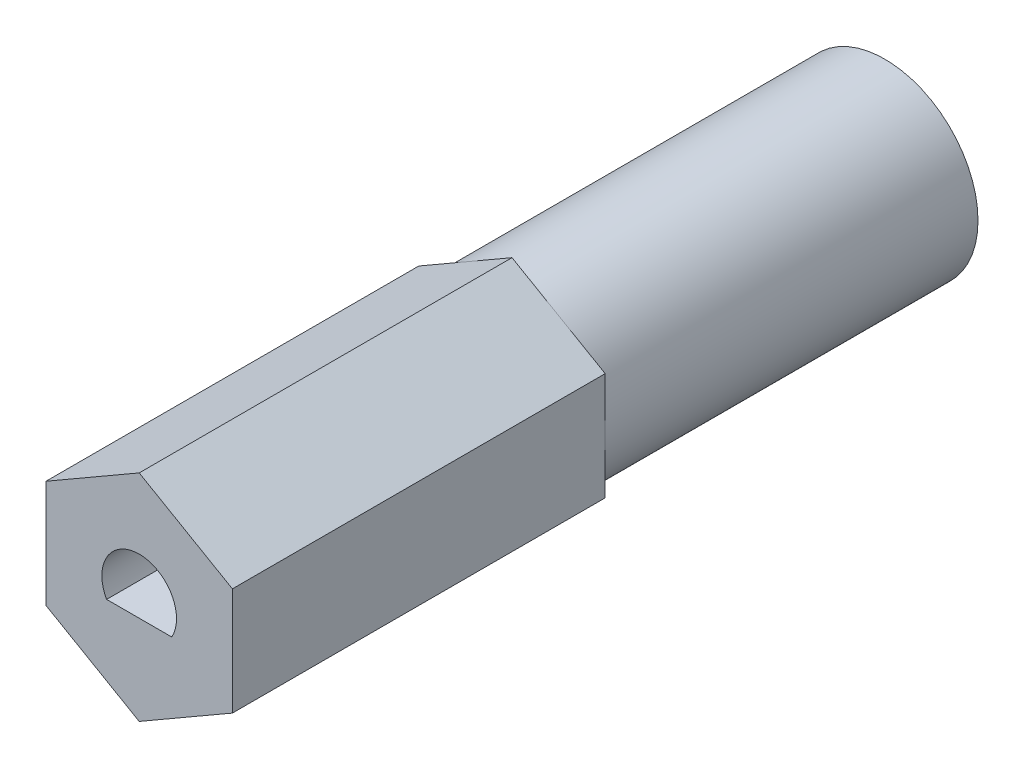
from build123d import *

# Parameters (mm, degrees)
BOSS_EXTRUDE1_DEPTH = 25.4
CUT_EXTRUDE1_DEPTH  = 5.08
SKETCH3_OUTSIDE_W   = 13.788
SKETCH3_OUTSIDE_H   = 14.77
SKETCH3_OUTSIDE_R   = 3.175
CUT_EXTRUDE2_DEPTH  = 13.7


with BuildPart() as part:
    # Sketch1 → Boss-Extrude1 (new body)
    with BuildSketch(Plane.XY):
        Polygon((0, 3.666174209), (-3.175, 1.833087105), (-3.175, -1.833087105), (0, -3.666174209), (3.175, -1.833087105), (3.175, 1.833087105), align=None)
    extrude(amount=-BOSS_EXTRUDE1_DEPTH)

    # Sketch2 → Cut-Extrude1 (cut)
    with BuildSketch(Plane.XY):
        with BuildLine():
            Line((-1.109862584, -0.6206744), (1.109862584, -0.6206744))
            ThreePointArc((1.109862584, -0.6206744), (0, 1.2716256), (-1.109862584, -0.6206744))
        make_face()
    extrude(amount=-CUT_EXTRUDE1_DEPTH, mode=Mode.SUBTRACT)

    # Sketch3 outside → Cut-Extrude2 (cut, through all)
    with BuildSketch(Plane.XY.offset(-12.7)):
        Rectangle(SKETCH3_OUTSIDE_W, SKETCH3_OUTSIDE_H)
        Circle(SKETCH3_OUTSIDE_R, mode=Mode.SUBTRACT)
    extrude(amount=-CUT_EXTRUDE2_DEPTH, mode=Mode.SUBTRACT)


solid = part.part
